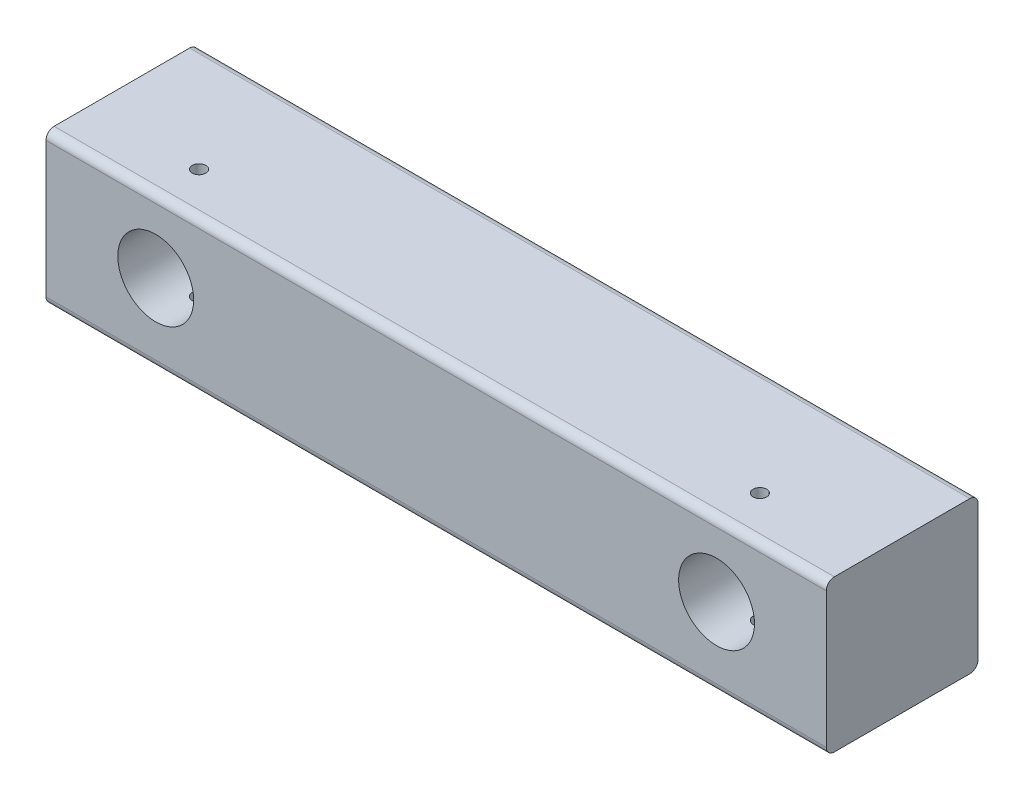
from build123d import *

# Parameters (mm, degrees)
SKETCH1_W                      = 457.2
SKETCH1_H                      = 88.9
BOSS_EXTRUDE1_DEPTH            = 88.9
SKETCH2_R                      = 22.225
CUT_EXTRUDE1_DEPTH             = 89.9
F_5_16_0_3125_DIAMETER_HOLE1_D = 7.9375
FILLET1_R                      = 4.7625


with BuildPart() as part:
    # Sketch1 → Boss-Extrude1 (new body)
    with BuildSketch(Plane.XY):
        with Locations((0, -527.543937925)):
            Rectangle(SKETCH1_W, SKETCH1_H)
    extrude(amount=-BOSS_EXTRUDE1_DEPTH)

    # Sketch2 → Cut-Extrude1 (cut, through all)
    with BuildSketch(Plane.XY):
        with Locations((164.309496882, -525.607187925)):
            Circle(SKETCH2_R)
        with Locations((-164.309496882, -525.607187925)):
            Circle(SKETCH2_R)
    extrude(amount=-CUT_EXTRUDE1_DEPTH, mode=Mode.SUBTRACT)

    # 5/16 (0.3125) Diameter Hole1 (through all)
    with Locations(Plane(origin=(0, -483.093937925, 0), x_dir=(1, 0, 0), z_dir=(0, 1, 0))):
        with Locations((-164.309496882, 25.4), (164.309496882, 25.4)):
            Hole(F_5_16_0_3125_DIAMETER_HOLE1_D / 2)

    # Fillet1
    fillet1_edges = [part.edges().sort_by_distance(p)[0] for p in [
        (0, -483.093937925, 0),
        (0, -571.993937925, -88.9),
        (0, -483.093937925, -88.9),
        (0, -571.993937925, 0),
    ]]
    fillet(fillet1_edges, radius=FILLET1_R)


solid = part.part
